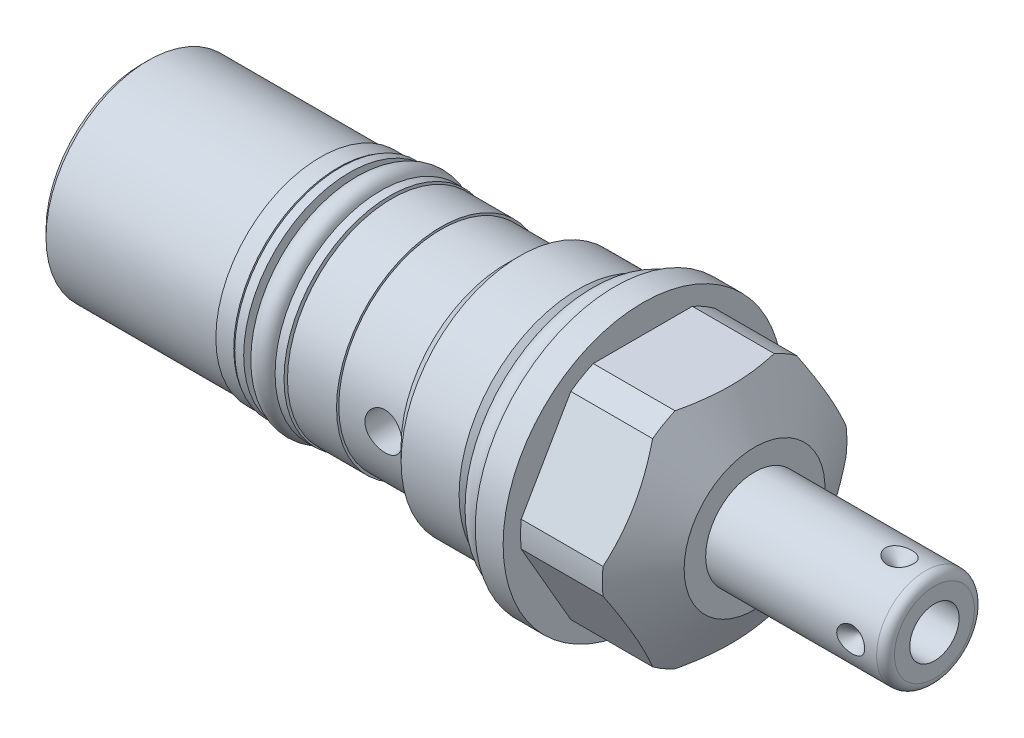
from build123d import *

# Parameters (mm, degrees)
SKETCH1_R           = 15.875
EXTRUDE1_DEPTH      = 15.875
EXTRUDE1_DEPTH_BACK = 53.7972
CUT_EXTRUDE1_REACH  = 55.797
SKETCH2_R           = 15.875
SKETCH2_R_2         = 13.49375
CUT_EXTRUDE3_REACH  = 14.7
SKETCH5_R           = 15.875
CUT_EXTRUDE5_REACH  = 14.7
SKETCH7_R           = 15.875
SKETCH7_R_2         = 13.8938
SKETCH12_W          = 6.1087
SKETCH12_H          = 2.0447
SKETCH14_W          = 0.254
SKETCH14_H          = 20.32
SKETCH14_H_2        = 7.3406
SKETCH15_R          = 1.4732
SKETCH16_W          = 2.1844
SKETCH16_H          = 1.016
SKETCH17_R          = 1.3081
CIRPATTERN1_COUNT   = 4
CHAMFER1_SIZE       = 0.762
SKETCH23_R          = 2.1082
CUT_EXTRUDE7_DEPTH  = 16.875


with BuildPart() as part:
    # Sketch1 → Extrude1 (new body, two sides)
    with BuildSketch(Plane(origin=(0, 0, 0), x_dir=(0, 0, -1), z_dir=(1, 0, 0))) as extrude1_sk:
        Circle(SKETCH1_R)
    extrude(amount=EXTRUDE1_DEPTH)
    extrude(extrude1_sk.sketch, amount=-EXTRUDE1_DEPTH_BACK)

    # Sketch2 → Cut-Extrude1 (cut, up to next)
    with BuildSketch(Plane(origin=(0, 0, 0), x_dir=(0, 0, -1), z_dir=(1, 0, 0)), mode=Mode.PRIVATE) as cut_extrude1_sk1:
        Circle(SKETCH2_R)
        Circle(SKETCH2_R_2, mode=Mode.SUBTRACT)
    cut_extrude1_tool1 = extrude(cut_extrude1_sk1.sketch, amount=-CUT_EXTRUDE1_REACH, mode=Mode.PRIVATE) & part.part
    add(cut_extrude1_tool1.solids().sort_by_distance((0, 0, 15.425987))[0], mode=Mode.SUBTRACT)

    # Sketch3 → Cut-Revolve1 (revolve, cut)
    with BuildSketch(Plane.XY, mode=Mode.PRIVATE) as cut_revolve1_sk:
        Polygon((11.32894398, 15.875), (15.875, 8.001), (15.875, 15.875), align=None)
    revolve(cut_revolve1_sk.sketch.rotate(Axis((-8.14577342, 0, 0), (1, 0, 0)), 270), axis=Axis((-8.14577342, 0, 0), (1, 0, 0)), mode=Mode.SUBTRACT)  # turned: the seam where the file's is

    # Cut-Extrude3: up to this cone (the profile starts inside it)
    cut_extrude3_end = Plane(origin=(3.175, 0, 0), z_dir=(-1, 0, 0)).offset(-17.319378504) * Cone(1.732e-06, 108.283356043, 62.51742376, align=(Align.CENTER, Align.CENTER, Align.MIN), mode=Mode.PRIVATE)
    # Sketch5 → Cut-Extrude3 (cut, up to the surface)
    with BuildSketch(Plane.ZY.offset(-3.175), mode=Mode.PRIVATE) as cut_extrude3_sk1:
        with Locations(Location((0, 0, 0), (0, 0, 180))):  # turned: the seam where the file's is
            Circle(SKETCH5_R)
        Polygon((-7.332348419, 12.7), (7.332348419, 12.7), (14.664696837, 0), (7.332348419, -12.7), (-7.332348419, -12.7), (-14.664696837, 0), align=None, mode=Mode.SUBTRACT)
    cut_extrude3_tool1 = extrude(cut_extrude3_sk1.sketch, amount=-CUT_EXTRUDE3_REACH, mode=Mode.PRIVATE) & cut_extrude3_end
    add(cut_extrude3_tool1.solids().sort_by_distance((3.175, 0, 15.425987))[0], mode=Mode.SUBTRACT)

    # Cut-Extrude5: up to this cone (the profile starts inside it)
    cut_extrude5_end = Plane(origin=(3.175, 0, 0), z_dir=(-1, 0, 0)).offset(-17.319378504) * Cone(1.732e-06, 108.283356043, 62.51742376, align=(Align.CENTER, Align.CENTER, Align.MIN), mode=Mode.PRIVATE)
    # Sketch7 → Cut-Extrude5 (cut, up to the surface)
    with BuildSketch(Plane.ZY.offset(-3.175), mode=Mode.PRIVATE) as cut_extrude5_sk1:
        with Locations(Location((0, 0, 0), (0, 0, 180))):  # turned: the seam where the file's is
            Circle(SKETCH7_R)
        Circle(SKETCH7_R_2, mode=Mode.SUBTRACT)
    cut_extrude5_tool1 = extrude(cut_extrude5_sk1.sketch, amount=-CUT_EXTRUDE5_REACH, mode=Mode.PRIVATE) & cut_extrude5_end
    add(cut_extrude5_tool1.solids().sort_by_distance((3.175, 0, 15.425987))[0], mode=Mode.SUBTRACT)

    # Sketch9 → Cut-Revolve3 (revolve, cut)
    with BuildSketch(Plane.XY, mode=Mode.PRIVATE) as cut_revolve3_sk:
        Polygon((0, 13.49375), (0, 12.0015), (-2.7178, 12.0015), (-4.21005, 13.49375), align=None)
    revolve(cut_revolve3_sk.sketch.rotate(Axis((-4.4205525, 0, 0), (1, 0, 0)), 90), axis=Axis((-4.4205525, 0, 0), (1, 0, 0)), mode=Mode.SUBTRACT)  # turned: the seam where the file's is

    # Sketch10 → Cut-Revolve4 (revolve, cut)
    with BuildSketch(Plane.XY, mode=Mode.PRIVATE) as cut_revolve4_sk:
        Polygon((-10.80135, 13.49375), (-12.4206, 11.8745), (-53.7972, 11.8745), (-53.7972, 13.49375), align=None)
    revolve(cut_revolve4_sk.sketch.rotate(Axis((-55.9469925, 0, 0), (1, 0, 0)), 90), axis=Axis((-55.9469925, 0, 0), (1, 0, 0)), mode=Mode.SUBTRACT)  # turned: the seam where the file's is

    # Sketch12 → Cut-Revolve6 (revolve, cut)
    with BuildSketch(Plane.XY, mode=Mode.PRIVATE) as cut_revolve6_sk:
        with Locations((-28.39085, 10.85215)):
            Rectangle(SKETCH12_W, SKETCH12_H)
    revolve(cut_revolve6_sk.sketch.rotate(Axis((-31.750635, 0, 0), (1, 0, 0)), 90), axis=Axis((-31.750635, 0, 0), (1, 0, 0)), mode=Mode.SUBTRACT)  # turned: the seam where the file's is

    # Sketch14 → Cut-Revolve8 (revolve, cut)
    with BuildSketch(Plane(origin=(0, 0, 0), x_dir=(0, -1, 0), z_dir=(0, 0, 1)), mode=Mode.PRIVATE) as cut_revolve8_sk:
        with Locations((11.7475, -43.6372)):
            Rectangle(SKETCH14_W, SKETCH14_H)
        with Locations((11.7475, -16.0909)):
            Rectangle(SKETCH14_W, SKETCH14_H_2)
    revolve(cut_revolve8_sk.sketch.rotate(Axis((-55.86603, 0, 0), (1, 0, 0)), 270), axis=Axis((-55.86603, 0, 0), (1, 0, 0)), mode=Mode.SUBTRACT)  # turned: the seam where the file's is

    # Sketch16 → Revolve2 (revolve)
    with BuildSketch(Plane(origin=(0, 0, 0), x_dir=(0, -1, 0), z_dir=(0, 0, 1)), mode=Mode.PRIVATE) as revolve2_sk:
        with Locations((10.922, -26.0985)):
            Rectangle(SKETCH16_W, SKETCH16_H)
        with Locations((10.922, -30.6832)):
            Rectangle(SKETCH16_W, SKETCH16_H)
    revolve(revolve2_sk.sketch.rotate(Axis((-31.471235, 0, 0), (1, 0, 0)), 270), axis=Axis((-31.471235, 0, 0), (1, 0, 0)))  # turned: the seam where the file's is

    # S2D0001 → Revolve4 (revolve)
    with BuildSketch(Plane(origin=(0, 0, 0), x_dir=(0, -1, 0), z_dir=(0, 0, 1)), mode=Mode.PRIVATE) as revolve4_sk:
        with BuildLine():
            Line((0, 15.875), (-5.55625, 15.875))
            Line((-5.55625, 15.875), (-5.55625, 35.306))
            ThreePointArc((-5.55625, 35.306), (-5.25867049, 36.02442049), (-4.54025, 36.322))
            Line((-4.54025, 36.322), (0, 36.322))
            Line((0, 36.322), (0, 15.875))
        make_face()
    revolve(revolve4_sk.sketch.rotate(Axis((7.265766347, 0, 0), (1, 0, 0)), 90), axis=Axis((7.265766347, 0, 0), (1, 0, 0)))  # turned: the seam where the file's is

    # Sketch19 → Cut-Revolve9 (revolve, cut)
    with BuildSketch(Plane(origin=(36.322, -2.8067, 0), x_dir=(0, -1, 0), z_dir=(0, 0, 1)), mode=Mode.PRIVATE) as cut_revolve9_sk:
        Polygon((0, 0), (0, -10.16), (-2.8067, -11.846435499), (-2.8067, 0), align=None)
    revolve(cut_revolve9_sk.sketch.rotate(Axis((17.699325537, 0, 0), (1, 0, 0)), 270), axis=Axis((17.699325537, 0, 0), (1, 0, 0)), mode=Mode.SUBTRACT)  # turned: the seam where the file's is

    # S2D0002 → Cut-Revolve10 (revolve, cut)
    with BuildSketch(Plane(origin=(32.3596, 0, -5.55625), x_dir=(1, 0, 0), z_dir=(0, 1, 0)), mode=Mode.PRIVATE) as cut_revolve10_sk:
        Polygon((0, 0), (1.5875, 0), (0, -1.5875), align=None)
    cut_revolve10 = revolve(cut_revolve10_sk.sketch.rotate(Axis((32.3596, 0, -2.191027232), (0, 0, -1)), 180), axis=Axis((32.3596, 0, -2.191027232), (0, 0, -1)), mode=Mode.SUBTRACT)  # turned: the seam where the file's is

    # CirPattern1: Cut-Revolve10 ×4 about axis
    cirpattern1_axis = Axis((7.265766347, 0, 0), (-1, 0, 0))
    for i in range(1, CIRPATTERN1_COUNT):
        add(cut_revolve10.rotate(cirpattern1_axis, i * 360 / CIRPATTERN1_COUNT), mode=Mode.SUBTRACT)

    # Chamfer1
    chamfer1_edges = [part.edges().sort_by_distance(p)[0] for p in [
        (-53.7972, 0, -11.6205),
    ]]
    chamfer(chamfer1_edges, length=CHAMFER1_SIZE)

    # Sketch23 → Cut-Extrude7 (cut, through all)
    with BuildSketch(Plane.XY):
        with Locations((-14.6812, 0)):
            Circle(SKETCH23_R)
    extrude(amount=CUT_EXTRUDE7_DEPTH, mode=Mode.SUBTRACT)

    # Sketch24 → Cut-Revolve11 (revolve, cut)
    with BuildSketch(Plane.XY, mode=Mode.PRIVATE) as cut_revolve11_sk:
        Polygon((-53.7972, 4.57835), (-51.7271, 4.138336662), (-51.043163338, 3.4544), (-42.0116, 3.4544), (-42.0116, 0), (-53.7972, 0), align=None)
    revolve(cut_revolve11_sk.sketch.rotate(Axis((0, 0, 0), (-1, 0, 0)), 270), axis=Axis((0, 0, 0), (-1, 0, 0)), mode=Mode.SUBTRACT)  # turned: the seam where the file's is


with BuildPart() as body_2:
    # Sketch15 → Revolve1 (revolve)
    with BuildSketch(Plane(origin=(0, 0, 0), x_dir=(0, -1, 0), z_dir=(0, 0, 1)), mode=Mode.PRIVATE) as revolve1_sk:
        with Locations((13.4747, -1.4732)):
            Circle(SKETCH15_R)
    revolve(revolve1_sk.sketch.rotate(Axis((-3.09372, 0, 0), (1, 0, 0)), 270), axis=Axis((-3.09372, 0, 0), (1, 0, 0)))  # turned: the seam where the file's is


with BuildPart() as body_3:
    # Sketch17 → Revolve3 (revolve)
    with BuildSketch(Plane(origin=(0, 0, 0), x_dir=(0, -1, 0), z_dir=(0, 0, 1)), mode=Mode.PRIVATE) as revolve3_sk:
        with Locations((11.1379, -28.39085)):
            Circle(SKETCH17_R)
    revolve(revolve3_sk.sketch.rotate(Axis((-31.750635, 0, 0), (1, 0, 0)), 270), axis=Axis((-31.750635, 0, 0), (1, 0, 0)))  # turned: the seam where the file's is


solid = Compound([part.part, body_2.part, body_3.part])
